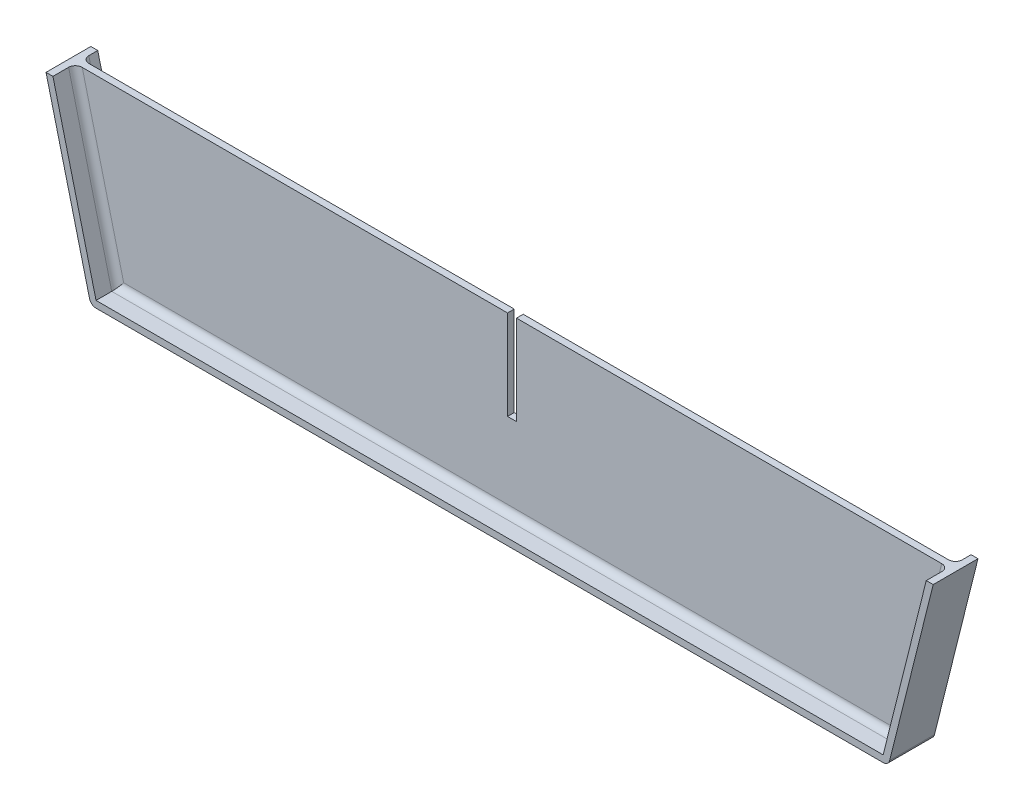
from build123d import *

# Parameters (mm, degrees)
BOSS_EXTRUDE2_DEPTH      = 1.5
BOSS_EXTRUDE3_DEPTH      = 5
BOSS_EXTRUDE3_DEPTH_BACK = 5
FILLET1_R                = 1.5


with BuildPart() as part:
    # Sketch1 → Boss-Extrude2 (new body)
    with BuildSketch(Plane.XY):
        Polygon((0, 0), (98, 0), (98, -20), (100, -20), (100, 0), (198, 0), (188, -40), (10, -40), align=None)
    extrude(amount=BOSS_EXTRUDE2_DEPTH)

    # Sketch5 → Boss-Extrude3 (add, two sides)
    with BuildSketch(Plane.XY.offset(1.5)) as boss_extrude3_sk:
        Polygon((186.82883539, -38.5), (196.45383539, 0), (198, 0), (188, -40), (10, -40), (0, 0), (1.54616461, 0), (11.17116461, -38.5), align=None)
    extrude(amount=BOSS_EXTRUDE3_DEPTH)
    extrude(boss_extrude3_sk.sketch, amount=-BOSS_EXTRUDE3_DEPTH_BACK)

    # Fillet1
    fillet1_edges = [part.edges().sort_by_distance(p)[0] for p in [
        (188, -40, 1.5),
        (10, -40, 1.5),
        (191.64133539, -19.25, 0),
        (99, -38.5, 0),
        (6.35866461, -19.25, 0),
        (6.35866461, -19.25, 1.5),
        (99, -38.5, 1.5),
        (191.64133539, -19.25, 1.5),
    ]]
    fillet(fillet1_edges, radius=FILLET1_R)


solid = part.part
